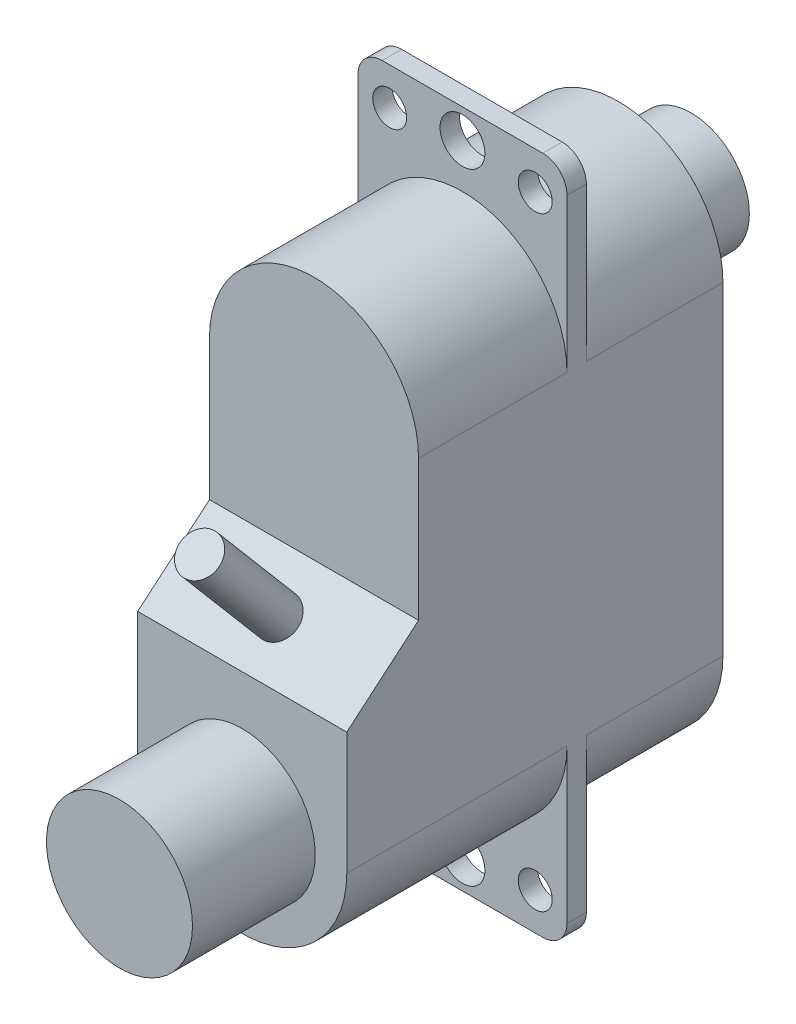
from build123d import *

# Parameters (mm, degrees)
SKETCH1_R               = 2.4
BOSS_EXTRUDE1_DEPTH     = 3
BOSS_EXTRUDE2_DEPTH     = 15.51
CUT_EXTRUDE1_DEPTH      = 26.936821316
CUT_EXTRUDE1_DEPTH_BACK = 26.936821316
SKETCH4_R               = 3.01
BOSS_EXTRUDE3_DEPTH     = 5.06
SKETCH5_R               = 0.925
SKETCH5_R_2             = 0.7
BOSS_EXTRUDE4_DEPTH     = 0.8
SKETCH6_R               = 0.823117729
BOSS_EXTRUDE5_DEPTH     = 5
CUT_EXTRUDE2_DEPTH      = 10


with BuildPart() as part:
    # Sketch1 → Boss-Extrude1 (new body)
    with BuildSketch(Plane.XY):
        Circle(SKETCH1_R)
    extrude(amount=BOSS_EXTRUDE1_DEPTH)

    # Sketch2 → Boss-Extrude2 (add)
    with BuildSketch(Plane.XY.offset(3)):
        with BuildLine():
            Line((4.31, 0), (4.31, -13.34))
            ThreePointArc((4.31, -13.34), (0, -17.65), (-4.31, -13.34))
            Line((-4.31, -13.34), (-4.31, 0))
            ThreePointArc((-4.31, 0), (0, 4.31), (4.31, 0))
        make_face()
    extrude(amount=BOSS_EXTRUDE2_DEPTH)

    # Sketch3 → Cut-Extrude1 (cut, two sides: drawn at the far end of the back side and taken through both)
    with BuildSketch(Plane(origin=(0, 0, 0), x_dir=(0, 0, -1), z_dir=(1, 0, 0)).offset(-CUT_EXTRUDE1_DEPTH_BACK)):
        Polygon((-18.51, 4.31), (-15.55, 4.31), (-15.55, -5.79), (-18.51, -8.3), align=None)
    extrude(amount=CUT_EXTRUDE1_DEPTH + CUT_EXTRUDE1_DEPTH_BACK, mode=Mode.SUBTRACT)

    # Sketch4 → Boss-Extrude3 (add)
    with BuildSketch(Plane.XY.offset(18.51)):
        with Locations((0, -13.34)):
            Circle(SKETCH4_R)
    extrude(amount=BOSS_EXTRUDE3_DEPTH)

    # Sketch5 → Boss-Extrude4 (add)
    with BuildSketch(Plane(origin=(0, 0, 8.63), x_dir=(-1, 0, 0), z_dir=(0, 0, -1))):
        with BuildLine():
            Line((-3.31, 7.33), (3.31, 7.33))
            ThreePointArc((3.31, 7.33), (4.017106781, 7.037106781), (4.31, 6.33))
            Line((4.31, 6.33), (4.31, -19.67))
            ThreePointArc((4.31, -19.67), (4.017106781, -20.377106781), (3.31, -20.67))
            Line((3.31, -20.67), (-3.31, -20.67))
            ThreePointArc((-3.31, -20.67), (-4.017106781, -20.377106781), (-4.31, -19.67))
            Line((-4.31, -19.67), (-4.31, 6.33))
            ThreePointArc((-4.31, 6.33), (-4.017106781, 7.037106781), (-3.31, 7.33))
        make_face()
        with Locations((0, 6.13)):
            Circle(SKETCH5_R, mode=Mode.SUBTRACT)
        with Locations((3, 5.79076381)):
            Circle(SKETCH5_R_2, mode=Mode.SUBTRACT)
        with Locations((-3, 5.79076381)):
            Circle(SKETCH5_R_2, mode=Mode.SUBTRACT)
        with Locations((3, -19.13076381)):
            Circle(SKETCH5_R_2, mode=Mode.SUBTRACT)
        with Locations((0, -19.47)):
            Circle(SKETCH5_R, mode=Mode.SUBTRACT)
        with Locations((-3, -19.13076381)):
            Circle(SKETCH5_R_2, mode=Mode.SUBTRACT)
    extrude(amount=-BOSS_EXTRUDE4_DEPTH)

    # Sketch6 → Boss-Extrude5 (add)
    with BuildSketch(Plane(origin=(0, 4.302344091, 3.64827151), x_dir=(1, 0, 0), z_dir=(0, 0.7627017002465386, 0.6467504282495988))):
        with Locations((0, -17.550441075)):
            Circle(SKETCH6_R)
    extrude(amount=BOSS_EXTRUDE5_DEPTH)

    # Sketch7 → Cut-Extrude2 (cut)
    with BuildSketch(Plane(origin=(0, 0, 8.63), x_dir=(-1, 0, 0), z_dir=(0, 0, -1))):
        with BuildLine():
            Line((2.313724821, -18.992827668), (1.90235458, -21.039522477))
            Line((1.90235458, -21.039522477), (5.963625728, -21.039522477))
            Line((5.963625728, -21.039522477), (5.695977486, -18.025570536))
            Line((5.695977486, -18.025570536), (2.852857547, -18.446403453))
            ThreePointArc((2.852857547, -18.446403453), (2.491968028, -18.629511021), (2.313724821, -18.992827668))
        make_face()
    extrude(amount=-CUT_EXTRUDE2_DEPTH, mode=Mode.SUBTRACT)


solid = part.part
